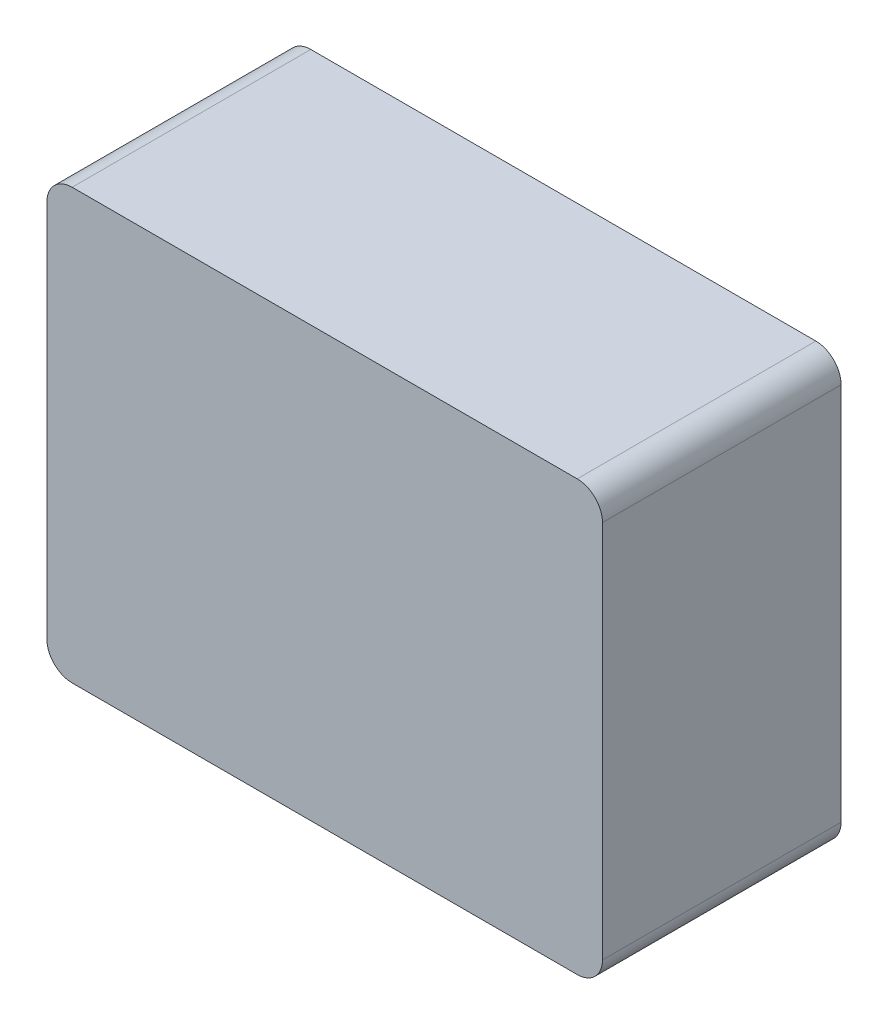
from build123d import *

# Parameters (mm, degrees)
SKETCH1_W           = 44
SKETCH1_H           = 18.9
BOSS_EXTRUDE1_DEPTH = 34
FILLET1_R           = 2
SKETCH2_R           = 1
CUT_EXTRUDE1_DEPTH  = 3.5


with BuildPart() as part:
    # Sketch1 → Boss-Extrude1 (new body)
    with BuildSketch(Plane(origin=(0, 0, 0), x_dir=(1, 0, 0), z_dir=(0, 1, 0))):
        with Locations((22, 9.45)):
            Rectangle(SKETCH1_W, SKETCH1_H)
    extrude(amount=BOSS_EXTRUDE1_DEPTH)

    # Fillet1
    fillet1_edges = [part.edges().sort_by_distance(p)[0] for p in [
        (44, 34, -9.45),
        (0, 34, -9.45),
        (44, 0, -9.45),
        (0, 0, -9.45),
    ]]
    fillet(fillet1_edges, radius=FILLET1_R)

    # Sketch2 → Cut-Extrude1 (cut)
    with BuildSketch(Plane(origin=(0, 0, 0), x_dir=(-1, 0, 0), z_dir=(0, -1, 0))):
        with Locations((-11, 3.02)):
            Circle(SKETCH2_R)
        with Locations((-33, 3.02)):
            Circle(SKETCH2_R)
        with Locations((-11, 15.02)):
            Circle(SKETCH2_R)
        with Locations((-33, 15.02)):
            Circle(SKETCH2_R)
    extrude(amount=-CUT_EXTRUDE1_DEPTH, mode=Mode.SUBTRACT)


solid = part.part
